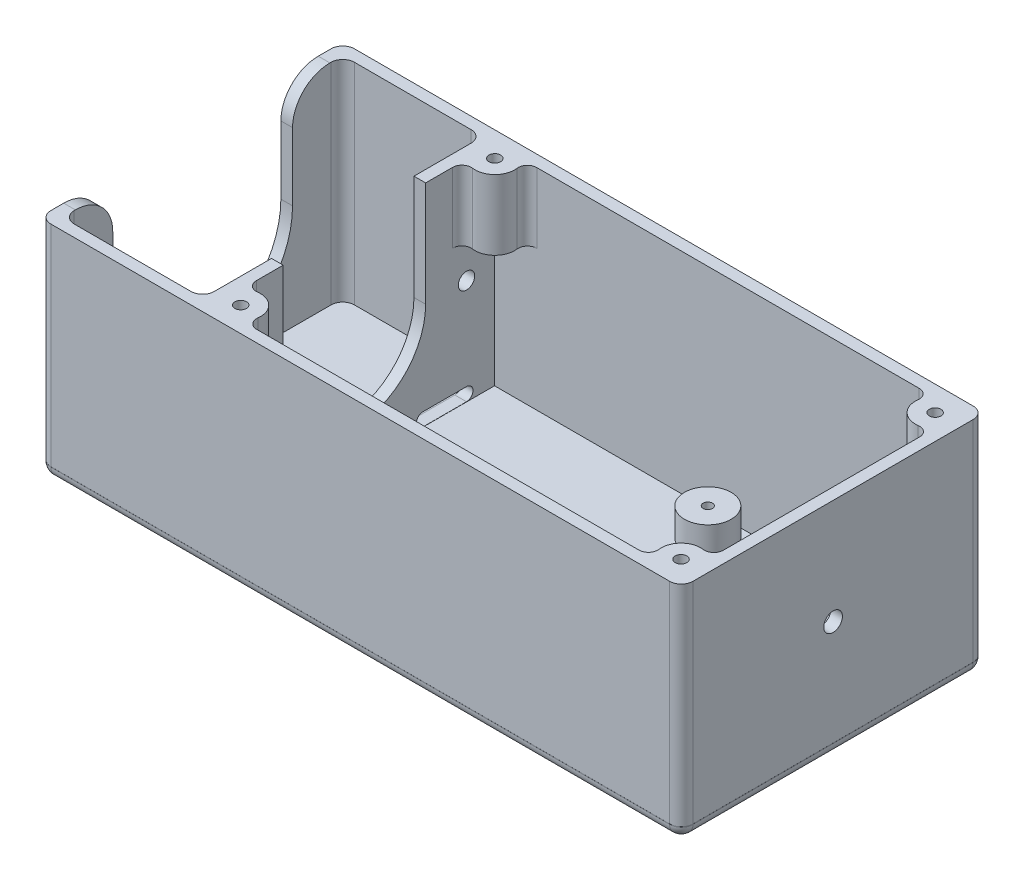
from build123d import *

# Parameters (mm, degrees)
SKETCH_1_R          = 1.25
EXTRUDE_1_DEPTH     = 45
EXTRUDE_2_DEPTH     = 2.5
FILLET_1_R          = 2.4
CUT_EXTRUDE_1_REACH = 107.011
SKETCH_4_R          = 1.75
SKETCH_5_W          = 60
SKETCH_5_H          = 30.019734177
CUT_EXTRUDE_2_DEPTH = 100
SKETCH_7_R          = 2
CUT_EXTRUDE_3_DEPTH = 2.5
SKETCH_8_R          = 5
SKETCH_8_R_2        = 1
EXTRUDE_7_DEPTH     = 6
CUT_EXTRUDE_4_REACH = 139.511


with BuildPart() as part:
    # Эскиз1 → Бобышка-Вытянуть1 (new body)
    with BuildSketch(Plane(origin=(0, 0, 0), x_dir=(1, 0, 0), z_dir=(0, 1, 0))):
        with BuildLine():
            Line((-82.5, 32.5), (50, 32.5))
            ThreePointArc((50, 32.5), (51.767766953, 31.767766953), (52.5, 30))
            Line((52.5, 30), (52.5, -30))
            ThreePointArc((52.5, -30), (51.767766953, -31.767766953), (50, -32.5))
            Line((50, -32.5), (-82.5, -32.5))
            ThreePointArc((-82.5, -32.5), (-84.267766953, -31.767766953), (-85, -30))
            Line((-85, -30), (-85, 30))
            ThreePointArc((-85, 30), (-84.267766953, 31.767766953), (-82.5, 32.5))
        make_face()
        with Locations((-47.144457485, 27.207649218)):
            Circle(SKETCH_1_R, mode=Mode.SUBTRACT)
        with Locations((47.144457485, -27.207649218)):
            Circle(SKETCH_1_R, mode=Mode.SUBTRACT)
        with Locations((47.144457485, 27.207649218)):
            Circle(SKETCH_1_R, mode=Mode.SUBTRACT)
        with Locations((-47.144457485, -27.207649218)):
            Circle(SKETCH_1_R, mode=Mode.SUBTRACT)
        with BuildLine():
            Line((-40.944886513, 30), (40.944886513, 30))
            ThreePointArc((40.944886513, 30), (42.446070129, 29.321532349), (42.928749224, 27.74644775))
            ThreePointArc((42.928749224, 27.74644775), (44.154618836, 24.187158388), (47.726226395, 22.997655757))
            ThreePointArc((47.726226395, 22.997655757), (49.313859351, 22.524386076), (50, 21.016482364))
            Line((50, 21.016482364), (50, -21.016482364))
            ThreePointArc((50, -21.016482364), (49.313859351, -22.524386076), (47.726226395, -22.997655757))
            ThreePointArc((47.726226395, -22.997655757), (44.154618836, -24.187158388), (42.928749224, -27.74644775))
            ThreePointArc((42.928749224, -27.74644775), (42.446070129, -29.321532349), (40.944886513, -30))
            Line((40.944886513, -30), (-40.944886513, -30))
            ThreePointArc((-40.944886513, -30), (-42.446070129, -29.321532349), (-42.928749224, -27.74644775))
            ThreePointArc((-42.928749224, -27.74644775), (-44.154618836, -24.187158388), (-47.726226395, -22.997655757))
            ThreePointArc((-47.726226395, -22.997655757), (-49.313859351, -22.524386076), (-50, -21.016482364))
            Line((-50, -21.016482364), (-50, 21.016482364))
            ThreePointArc((-50, 21.016482364), (-49.313859351, 22.524386076), (-47.726226395, 22.997655757))
            ThreePointArc((-47.726226395, 22.997655757), (-44.154618836, 24.187158388), (-42.928749224, 27.74644775))
            ThreePointArc((-42.928749224, 27.74644775), (-42.446070129, 29.321532349), (-40.944886513, 30))
        make_face(mode=Mode.SUBTRACT)
        with BuildLine():
            Line((-80, 30), (-55, 30))
            ThreePointArc((-55, 30), (-53.232233047, 29.267766953), (-52.5, 27.5))
            Line((-52.5, 27.5), (-52.5, -27.5))
            ThreePointArc((-52.5, -27.5), (-53.232233047, -29.267766953), (-55, -30))
            Line((-55, -30), (-80, -30))
            ThreePointArc((-80, -30), (-81.767766953, -29.267766953), (-82.5, -27.5))
            Line((-82.5, -27.5), (-82.5, 27.5))
            ThreePointArc((-82.5, 27.5), (-81.767766953, 29.267766953), (-80, 30))
        make_face(mode=Mode.SUBTRACT)
    extrude(amount=EXTRUDE_1_DEPTH)

    # Эскиз2 → Бобышка-Вытянуть2 (add)
    with BuildSketch(Plane.XZ):
        with BuildLine():
            Line((-82.499025459, -32.487948089), (50.01119166, -32.487948089))
            ThreePointArc((50.01119166, -32.487948089), (51.778958613, -31.755715042), (52.51119166, -29.987948089))
            Line((52.51119166, -29.987948089), (52.51119166, 30.012051911))
            ThreePointArc((52.51119166, 30.012051911), (51.778958613, 31.779818864), (50.01119166, 32.512051911))
            Line((50.01119166, 32.512051911), (-82.499025459, 32.512051911))
            ThreePointArc((-82.499025459, 32.512051911), (-84.266792412, 31.779818864), (-84.999025459, 30.012051911))
            Line((-84.999025459, 30.012051911), (-84.999025459, -29.987948089))
            ThreePointArc((-84.999025459, -29.987948089), (-84.266792412, -31.755715042), (-82.499025459, -32.487948089))
        make_face()
    extrude(amount=EXTRUDE_2_DEPTH)

    # Скругление1
    fillet_1_edges = [part.edges().sort_by_distance(p)[0] for p in [
        (51.778958613, -2.5, -31.755715042),
        (52.51119166, -2.5, 0.012051911),
        (51.778958613, -2.5, 31.779818864),
        (-16.2439169, -2.5, 32.512051911),
        (-84.266792412, -2.5, 31.779818864),
        (-84.999025459, -2.5, 0.012051911),
        (-84.266792412, -2.5, -31.755715042),
        (-16.2439169, -2.5, -32.487948089),
    ]]
    fillet(fillet_1_edges, radius=FILLET_1_R)

    # Эскиз4 → Вырез-Вытянуть1 (cut, up to next)
    with BuildSketch(Plane.ZY.offset(52.5), mode=Mode.PRIVATE) as cut_extrude_1_sk1:
        with Locations((-24, 22.5)):
            Circle(SKETCH_4_R)
    cut_extrude_1_tool1 = extrude(cut_extrude_1_sk1.sketch, amount=-CUT_EXTRUDE_1_REACH, mode=Mode.PRIVATE) & part.part
    add(cut_extrude_1_tool1.solids().sort_by_distance((-52.5, 22.5, -24))[0], mode=Mode.SUBTRACT)
    # Эскиз4 → Вырез-Вытянуть1 (cut, up to next)
    with BuildSketch(Plane.ZY.offset(52.5), mode=Mode.PRIVATE) as cut_extrude_1_sk2:
        with Locations((24, 22.5)):
            Circle(SKETCH_4_R)
    cut_extrude_1_tool2 = extrude(cut_extrude_1_sk2.sketch, amount=-CUT_EXTRUDE_1_REACH, mode=Mode.PRIVATE) & part.part
    add(cut_extrude_1_tool2.solids().sort_by_distance((-52.5, 22.5, 24))[0], mode=Mode.SUBTRACT)
    # Эскиз4 → Вырез-Вытянуть1 (cut, up to next)
    with BuildSketch(Plane.ZY.offset(52.5), mode=Mode.PRIVATE) as cut_extrude_1_sk3:
        with BuildLine():
            Line((-15.25, 22.5), (-15.25, 45))
            Line((-15.25, 45), (15.25, 45))
            Line((15.25, 45), (15.25, 22.5))
            ThreePointArc((15.25, 22.5), (0, 7.25), (-15.25, 22.5))
        make_face()
    cut_extrude_1_tool3 = extrude(cut_extrude_1_sk3.sketch, amount=-CUT_EXTRUDE_1_REACH, mode=Mode.PRIVATE) & part.part
    add(cut_extrude_1_tool3.solids().sort_by_distance((-52.5, 27.593324, 0))[0], mode=Mode.SUBTRACT)
    # Эскиз4 → Вырез-Вытянуть1 (cut, up to next)
    with BuildSketch(Plane.ZY.offset(52.5), mode=Mode.PRIVATE) as cut_extrude_1_sk4:
        with BuildLine():
            Line((14.671963407, 2.845780587), (24, 2.845780587))
            ThreePointArc((24, 2.845780587), (25.400762709, 1.445017878), (24, 0.044255169))
            Line((24, 0.044255169), (14.671963407, 0.044255169))
            ThreePointArc((14.671963407, 0.044255169), (13.271200698, 1.445017878), (14.671963407, 2.845780587))
        make_face()
    cut_extrude_1_tool4 = extrude(cut_extrude_1_sk4.sketch, amount=-CUT_EXTRUDE_1_REACH, mode=Mode.PRIVATE) & part.part
    add(cut_extrude_1_tool4.solids().sort_by_distance((-52.5, 1.445018, 19.335982))[0], mode=Mode.SUBTRACT)
    # Эскиз4 → Вырез-Вытянуть1 (cut, up to next)
    with BuildSketch(Plane.ZY.offset(52.5), mode=Mode.PRIVATE) as cut_extrude_1_sk5:
        with BuildLine():
            Line((-14.671963407, 2.845780587), (-24, 2.845780587))
            ThreePointArc((-24, 2.845780587), (-25.400762709, 1.445017878), (-24, 0.044255169))
            Line((-24, 0.044255169), (-14.671963407, 0.044255169))
            ThreePointArc((-14.671963407, 0.044255169), (-13.271200698, 1.445017878), (-14.671963407, 2.845780587))
        make_face()
    cut_extrude_1_tool5 = extrude(cut_extrude_1_sk5.sketch, amount=-CUT_EXTRUDE_1_REACH, mode=Mode.PRIVATE) & part.part
    add(cut_extrude_1_tool5.solids().sort_by_distance((-52.5, 1.445018, -19.335982))[0], mode=Mode.SUBTRACT)

    # Эскиз5 → Вырез-Вытянуть2 (cut)
    with BuildSketch(Plane(origin=(-50, 0, 0), x_dir=(0, 0, -1), z_dir=(1, 0, 0))):
        with Locations((0, 15.009867089)):
            Rectangle(SKETCH_5_W, SKETCH_5_H)
    extrude(amount=CUT_EXTRUDE_2_DEPTH, mode=Mode.SUBTRACT)

    # Эскиз7 → Вырез-Вытянуть3 (cut)
    with BuildSketch(Plane(origin=(52.5, 0, 0), x_dir=(0, 0, -1), z_dir=(1, 0, 0))):
        with Locations((0, 22.5)):
            Circle(SKETCH_7_R)
    extrude(amount=-CUT_EXTRUDE_3_DEPTH, mode=Mode.SUBTRACT)

    # Эскиз8 → Бобышка-Вытянуть7 (add)
    with BuildSketch(Plane(origin=(0, 0, 0), x_dir=(1, 0, 0), z_dir=(0, 1, 0))):
        with Locations((1.091418082, 24.583435137)):
            Circle(SKETCH_8_R)
        with Locations((1.091418082, 24.583435137)):
            Circle(SKETCH_8_R_2, mode=Mode.SUBTRACT)
        with Locations((38.091418082, 24.583435137)):
            Circle(SKETCH_8_R)
        with Locations((38.091418082, 24.583435137)):
            Circle(SKETCH_8_R_2, mode=Mode.SUBTRACT)
        with Locations((38.091418082, -12.416564863)):
            Circle(SKETCH_8_R)
        with Locations((38.091418082, -12.416564863)):
            Circle(SKETCH_8_R_2, mode=Mode.SUBTRACT)
        with Locations((1.091418082, -12.416564863)):
            Circle(SKETCH_8_R)
        with Locations((1.091418082, -12.416564863)):
            Circle(SKETCH_8_R_2, mode=Mode.SUBTRACT)
    extrude(amount=EXTRUDE_7_DEPTH)

    # Эскиз10 → Вырез-Вытянуть4 (cut, up to next)
    with BuildSketch(Plane.ZY.offset(85), mode=Mode.PRIVATE) as cut_extrude_4_sk1:
        with BuildLine():
            Line((-19.25, 22.5), (-19.25, 37))
            ThreePointArc((-19.25, 37), (-21.593145751, 42.656854249), (-27.25, 45))
            Line((-27.25, 45), (27.25, 45))
            ThreePointArc((27.25, 45), (21.593145751, 42.656854249), (19.25, 37))
            Line((19.25, 37), (19.25, 22.5))
            ThreePointArc((19.25, 22.5), (0, 3.25), (-19.25, 22.5))
        make_face()
    cut_extrude_4_tool1 = extrude(cut_extrude_4_sk1.sketch, amount=-CUT_EXTRUDE_4_REACH, mode=Mode.PRIVATE) & part.part
    add(cut_extrude_4_tool1.solids().sort_by_distance((-85, 26.266593, 0))[0], mode=Mode.SUBTRACT)


solid = part.part
